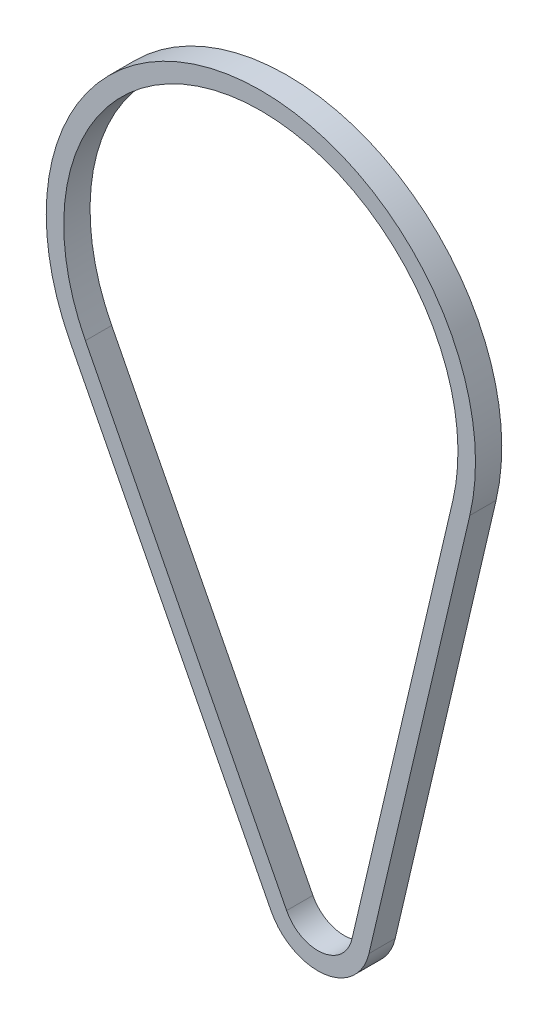
from build123d import *

# Parameters (mm, degrees)
EXTRUS_O_FINA1_DEPTH = 7.5


with BuildPart() as part:
    # Esboço2 → Extrusão-Fina1 (new, symmetric)
    with BuildSketch(Plane.XY):
        with BuildLine():
            Line((86.76192187, 238.475650619), (29.207001274, -6.852085563))
            ThreePointArc((29.207001274, -6.852085563), (3.632235594, -29.779302621), (-26.703688402, -13.671613867))
            Line((-26.703688402, -13.671613867), (-141.540060974, 210.629243374))
            ThreePointArc((-141.540060974, 210.629243374), (-47.331628675, 388.053819036), (86.76192187, 238.475650619))
        make_face()
        with BuildLine():
            Line((77.026254779, 240.75967914), (19.471334183, -4.568057042))
            ThreePointArc((19.471334183, -4.568057042), (2.421490396, -19.852868414), (-17.802458935, -9.114409245))
            Line((-17.802458935, -9.114409245), (-132.638831507, 215.186447997))
            ThreePointArc((-132.638831507, 215.186447997), (-46.120883477, 378.127384829), (77.026254779, 240.75967914))
        make_face(mode=Mode.SUBTRACT)
    extrude(amount=EXTRUS_O_FINA1_DEPTH, both=True)


solid = part.part
